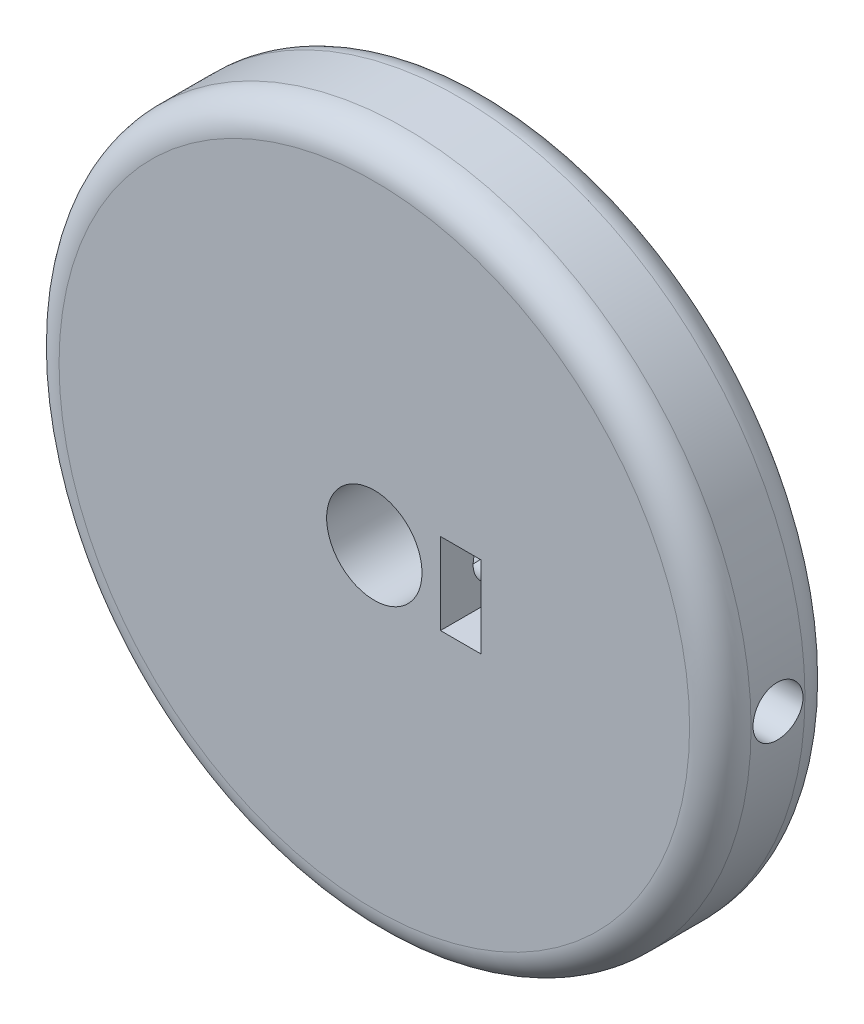
from build123d import *

# Parameters (mm, degrees)
SKETCH1_R               = 45
SKETCH1_R_2             = 6.2
BOSS_EXTRUDE1_DEPTH     = 7.5
SKETCH2_W               = 5.3
SKETCH2_H               = 10.6
CUT_EXTRUDE1_DEPTH      = 13
SKETCH3_R               = 3.25
CUT_EXTRUDE2_DEPTH      = 37.4
CUT_EXTRUDE2_DEPTH_BACK = 13
FILLET1_R               = 4


with BuildPart() as part:
    # Sketch1 → Boss-Extrude1 (new body, symmetric)
    with BuildSketch(Plane.XY):
        Circle(SKETCH1_R)
        Circle(SKETCH1_R_2, mode=Mode.SUBTRACT)
    extrude(amount=BOSS_EXTRUDE1_DEPTH, both=True)

    # Sketch2 → Cut-Extrude1 (cut)
    with BuildSketch(Plane.XY.offset(7.5)):
        with Locations((11.25, 0)):
            Rectangle(SKETCH2_W, SKETCH2_H)
    extrude(amount=-CUT_EXTRUDE1_DEPTH, mode=Mode.SUBTRACT)

    # Sketch3 → Cut-Extrude2 (cut, two sides)
    with BuildSketch(Plane(origin=(8.6, 0, 0), x_dir=(0, 0, -1), z_dir=(1, 0, 0))) as cut_extrude2_sk:
        Circle(SKETCH3_R)
    extrude(amount=CUT_EXTRUDE2_DEPTH, mode=Mode.SUBTRACT)
    extrude(cut_extrude2_sk.sketch, amount=-CUT_EXTRUDE2_DEPTH_BACK, mode=Mode.SUBTRACT)

    # Fillet1
    fillet1_edges = [part.edges().sort_by_distance(p)[0] for p in [
        (-45, 0, -7.5),
        (-45, 0, 7.5),
    ]]
    fillet(fillet1_edges, radius=FILLET1_R)


solid = part.part
